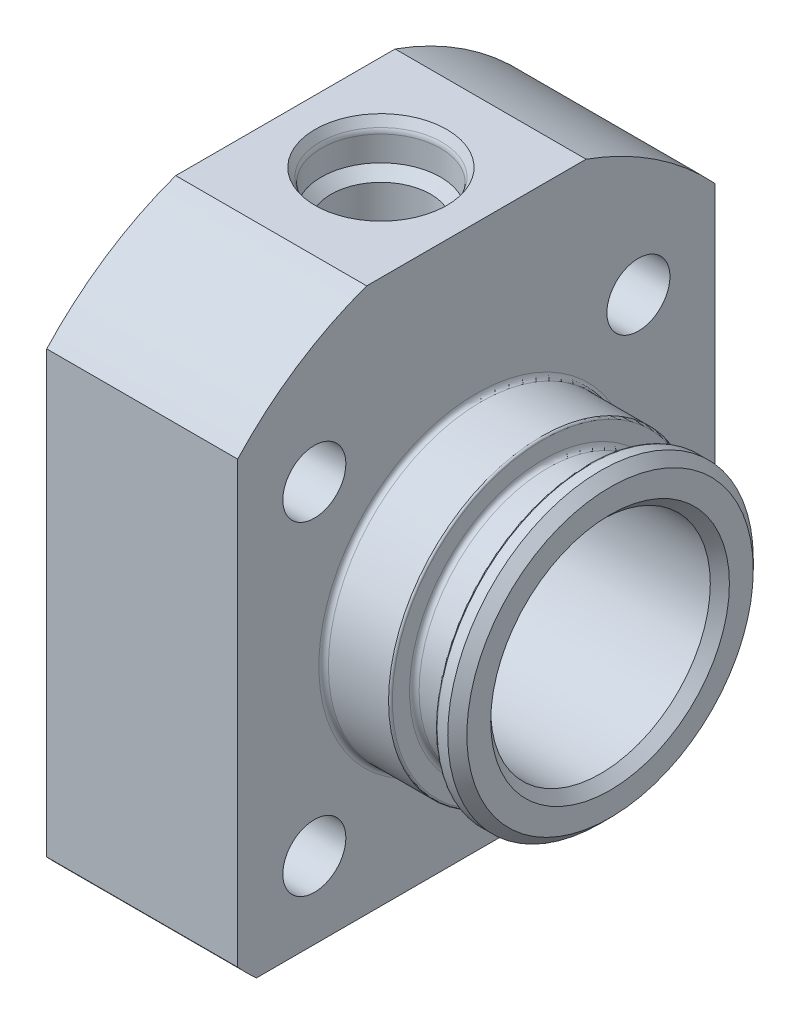
from build123d import *

# Parameters (mm, degrees)
SKETCH_2_OUTSIDE_W          = 91.15
SKETCH_2_OUTSIDE_H          = 91.15
CUT_EXTRUDE_1_DEPTH         = 35
HOLE_WIZARD_M61_D           = 6.6
HOLE_WIZARD_M61_CBORE_D     = 11
HOLE_WIZARD_M61_CBORE_DEPTH = 6.4
PATTERN_CIRCULAR_1_COUNT    = 4
SKETCH_11_OUTSIDE_W         = 69.532
SKETCH_11_OUTSIDE_H         = 76.532
CUT_EXTRUDE_2_DEPTH         = 9
CHAMFER_1_SIZE              = 1
FILLET_1_R                  = 0.2
FILLET_2_R                  = 0.5
FILLET_3_R                  = 0.5


with BuildPart() as part:
    # Эскиз1 → Повернуть1 (revolve)
    with BuildSketch(Plane.XY):
        Polygon((20, 34), (20, 16), (27, 16), (27, 13.5), (31.7, 13.5), (31.7, 16), (34, 16), (34, 11.5), (4, 11.5), (4, 0), (-10, 0), (-10, 9.5), (-9.598076211, 11), (0, 11), (0, 34), align=None)
    revolve(axis=Axis((0, 0, 0), (-1, 0, 0)))

    # Эскиз2 outside → Вырез-Вытянуть1 (cut, through all)
    with BuildSketch(Plane.ZY):
        Rectangle(SKETCH_2_OUTSIDE_W, SKETCH_2_OUTSIDE_H)
        with BuildLine():
            Line((-11.489125293, 32), (11.489125293, 32))
            ThreePointArc((11.489125293, 32), (18.786140377, 28.338682569), (25, 23.043437244))
            Line((25, 23.043437244), (25, -25))
            Line((25, -25), (-25, -25))
            Line((-25, -25), (-25, 23.043437244))
            ThreePointArc((-25, 23.043437244), (-18.786140377, 28.338682569), (-11.489125293, 32))
        make_face(mode=Mode.SUBTRACT)
    extrude(amount=-CUT_EXTRUDE_1_DEPTH, mode=Mode.SUBTRACT)

    # Sketch2 → Cut-Revolve1 (revolve, cut)
    with BuildSketch(Plane(origin=(-10, 0, 0), x_dir=(0, 0, -1), z_dir=(0, 1, 0))):
        with BuildLine():
            Line((0, 0), (0, -63.103445097))
            Line((0, -63.103445097), (-5.165, -60))
            Line((-5.165, -60), (-5.165, -13))
            Line((-5.165, -13), (-5.215, -13))
            Line((-5.215, -13), (-5.215, -5.035))
            Line((-5.215, -5.035), (-6.25, -4))
            Line((-6.25, -4), (-6.25, -1.393782217))
            ThreePointArc((-6.25, -1.393782217), (-6.284074174, -1.134963172), (-6.383974596, -0.893782217))
            Line((-6.383974596, -0.893782217), (-6.9, 0))
            Line((-6.9, 0), (0, 0))
        make_face()
    revolve(axis=Axis((-10, 0, 0), (-1, 0, 0)), mode=Mode.SUBTRACT)

    # Цековка для винта с внутренним шестигранником M61 (through all)
    with Locations(Plane.ZY):
        with Locations((16.970562748, 16.970562748)):
            hole_wizard_m61 = CounterBoreHole(HOLE_WIZARD_M61_D / 2, HOLE_WIZARD_M61_CBORE_D / 2, HOLE_WIZARD_M61_CBORE_DEPTH)

    # Круговой массив1: Цековка для винта с внутренним шестигранником M61 ×4 about axis
    pattern_circular_1_axis = Axis((0, 0, 0), (1, 0, 0))
    for i in range(1, PATTERN_CIRCULAR_1_COUNT):
        add(hole_wizard_m61.rotate(pattern_circular_1_axis, i * 360 / PATTERN_CIRCULAR_1_COUNT), mode=Mode.SUBTRACT)

    # Sketch22 → Cut-Revolve12 (revolve, cut)
    with BuildSketch(Plane(origin=(10, 32, 0), x_dir=(1, 0, 0), z_dir=(0, 0, 1))):
        with BuildLine():
            Line((0, 0), (0, -35.103445097))
            Line((0, -35.103445097), (-5.165, -32))
            Line((-5.165, -32), (-5.165, -13))
            Line((-5.165, -13), (-5.215, -13))
            Line((-5.215, -13), (-5.215, -5.035))
            Line((-5.215, -5.035), (-6.25, -4))
            Line((-6.25, -4), (-6.25, -1.393782217))
            ThreePointArc((-6.25, -1.393782217), (-6.284074174, -1.134963172), (-6.383974596, -0.893782217))
            Line((-6.383974596, -0.893782217), (-6.9, 0))
            Line((-6.9, 0), (0, 0))
        make_face()
    revolve(axis=Axis((10, 32, 0), (0, 1, 0)), mode=Mode.SUBTRACT)

    # Эскиз11 outside → Вырез-Вытянуть2 (cut)
    with BuildSketch(Plane.ZY.offset(10)):
        with Locations((0, 3.5)):
            Rectangle(SKETCH_11_OUTSIDE_W, SKETCH_11_OUTSIDE_H)
        Polygon((0, 10.969655115), (-9.5, 5.484827557), (-9.5, -5.484827557), (0, -10.969655115), (9.5, -5.484827557), (9.5, 5.484827557), align=None, mode=Mode.SUBTRACT)
    extrude(amount=-CUT_EXTRUDE_2_DEPTH, mode=Mode.SUBTRACT)

    # Фаска1
    chamfer_1_edges = [part.edges().sort_by_distance(p)[0] for p in [
        (34, -16, 0),
        (34, -11.5, 0),
    ]]
    chamfer(chamfer_1_edges, length=CHAMFER_1_SIZE)

    # Скругление1
    fillet_1_edges = [part.edges().sort_by_distance(p)[0] for p in [
        (27, -16, 0),
        (31.7, -16, 0),
    ]]
    fillet(fillet_1_edges, radius=FILLET_1_R)

    # Скругление2
    fillet_2_edges = [part.edges().sort_by_distance(p)[0] for p in [
        (27, -13.5, 0),
        (31.7, -13.5, 0),
    ]]
    fillet(fillet_2_edges, radius=FILLET_2_R)

    # Скругление3
    fillet_3_edges = [part.edges().sort_by_distance(p)[0] for p in [
        (20, -16, 0),
        (4, -11.5, 0),
    ]]
    fillet(fillet_3_edges, radius=FILLET_3_R)


solid = part.part
